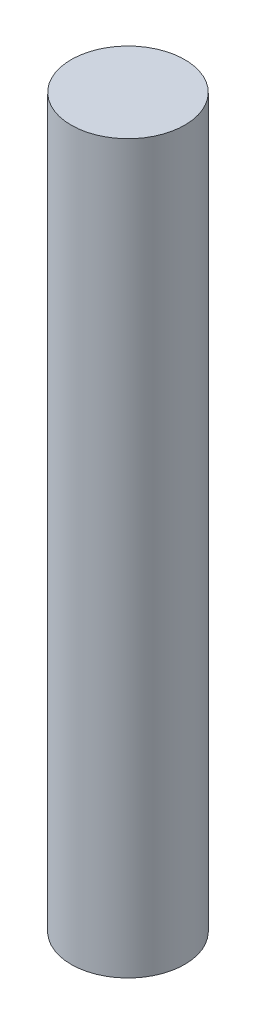
from build123d import *

# Parameters (mm, degrees)
SKETCH1_R           = 0.9921875
BOSS_EXTRUDE1_DEPTH = 12.7


with BuildPart() as part:
    # Sketch1 → Boss-Extrude1 (new body)
    with BuildSketch(Plane(origin=(0, 0, 0), x_dir=(1, 0, 0), z_dir=(0, 1, 0))):
        Circle(SKETCH1_R)
    extrude(amount=BOSS_EXTRUDE1_DEPTH)


solid = part.part
